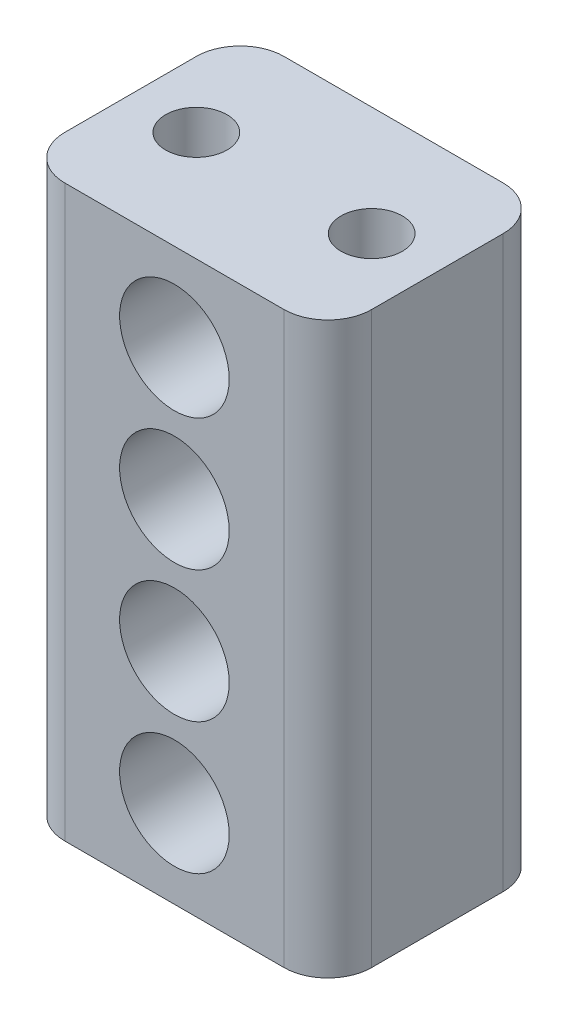
from build123d import *

# Parameters (mm, degrees)
SKETCH2_W           = 7
SKETCH2_H           = 13
SKETCH2_R           = 1.25
BOSS_EXTRUDE1_DEPTH = 5
FILLET1_R           = 1
SKETCH3_R           = 0.7
CUT_EXTRUDE1_DEPTH  = 3


with BuildPart() as part:
    # Sketch2 → Boss-Extrude1 (new body)
    with BuildSketch(Plane.XY):
        Rectangle(SKETCH2_W, SKETCH2_H)
        with Locations((0, 4.5)):
            Circle(SKETCH2_R, mode=Mode.SUBTRACT)
        with Locations((0, 1.5)):
            Circle(SKETCH2_R, mode=Mode.SUBTRACT)
        with Locations((0, -1.5)):
            Circle(SKETCH2_R, mode=Mode.SUBTRACT)
        with Locations((0, -4.5)):
            Circle(SKETCH2_R, mode=Mode.SUBTRACT)
    extrude(amount=BOSS_EXTRUDE1_DEPTH)

    # Fillet1
    fillet1_edges = [part.edges().sort_by_distance(p)[0] for p in [
        (-3.5, 0, 0),
        (3.5, 0, 0),
        (3.5, 0, 5),
        (-3.5, 0, 5),
    ]]
    fillet(fillet1_edges, radius=FILLET1_R)

    # Sketch3 → Cut-Extrude1 (cut)
    with BuildSketch(Plane(origin=(0, 6.5, 0), x_dir=(1, 0, 0), z_dir=(0, 1, 0))):
        with Locations((-2, -2.5)):
            Circle(SKETCH3_R)
        with Locations((2, -2.5)):
            Circle(SKETCH3_R)
    cut_extrude1 = extrude(amount=-CUT_EXTRUDE1_DEPTH, mode=Mode.SUBTRACT)

    # Mirror1: Cut-Extrude1 across plane
    add(cut_extrude1.mirror(Plane.ZX), mode=Mode.SUBTRACT)


solid = part.part
